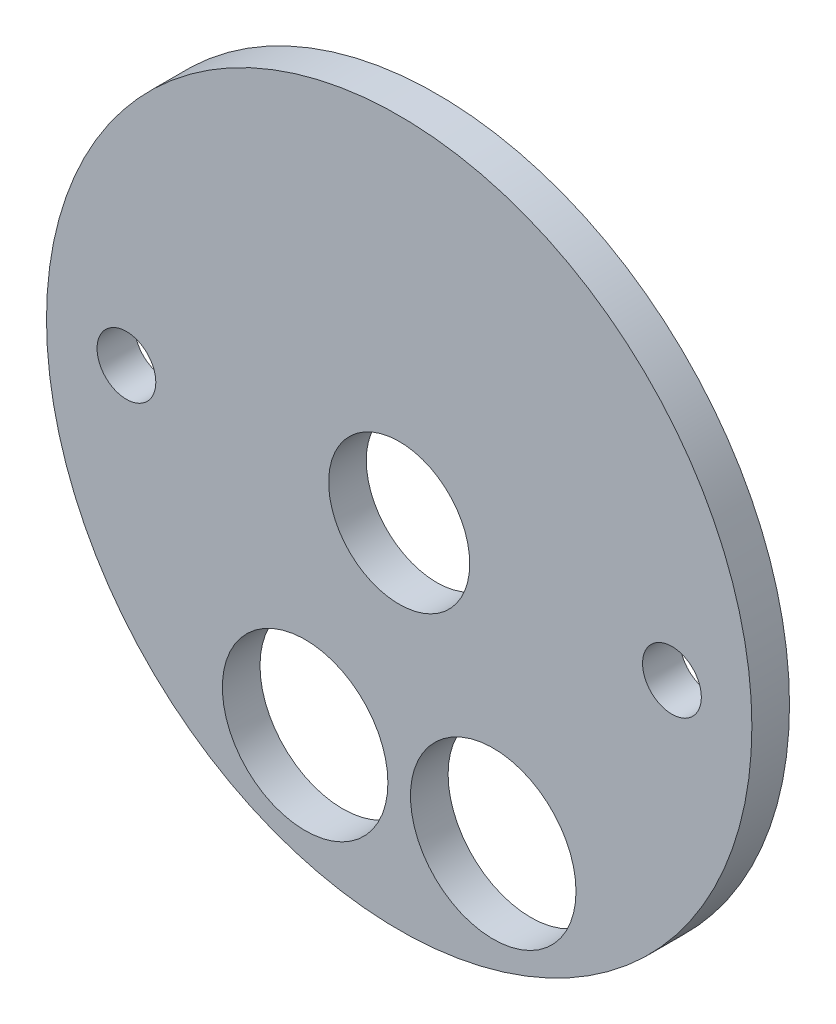
from build123d import *

# Parameters (mm, degrees)
SKETCH1_R           = 49.5046
BOSS_EXTRUDE1_DEPTH = 5.08
SKETCH2_R           = 47.625
BOSS_EXTRUDE2_DEPTH = 5.08
SKETCH3_R           = 11.176
SKETCH3_R_2         = 3.96875
SKETCH3_R_3         = 9.525
CUT_EXTRUDE1_DEPTH  = 11.16
SKETCH7_R           = 65.421404769
CUT_EXTRUDE3_DEPTH  = 5.08


with BuildPart() as part:
    # Sketch1 → Boss-Extrude1 (new body)
    with BuildSketch(Plane.XY):
        Circle(SKETCH1_R)
    extrude(amount=BOSS_EXTRUDE1_DEPTH)

    # Sketch2 → Boss-Extrude2 (add)
    with BuildSketch(Plane.XY.offset(5.08)):
        Circle(SKETCH2_R)
    extrude(amount=BOSS_EXTRUDE2_DEPTH)

    # Sketch3 → Cut-Extrude1 (cut, through all)
    with BuildSketch(Plane.XY.offset(10.16)):
        with Locations((-12.7, -31.166793627)):
            Circle(SKETCH3_R)
        with Locations((12.7, -31.166793627)):
            Circle(SKETCH3_R)
        with Locations((-36.83, 0)):
            Circle(SKETCH3_R_2)
        with Locations((36.83, 0)):
            Circle(SKETCH3_R_2)
        Circle(SKETCH3_R_3)
    extrude(amount=-CUT_EXTRUDE1_DEPTH, mode=Mode.SUBTRACT)

    # Sketch7 → Cut-Extrude3 (cut)
    with BuildSketch(Plane(origin=(0, 0, 0), x_dir=(-1, 0, 0), z_dir=(0, 0, -1))):
        Circle(SKETCH7_R)
    extrude(amount=-CUT_EXTRUDE3_DEPTH, mode=Mode.SUBTRACT)


solid = part.part
